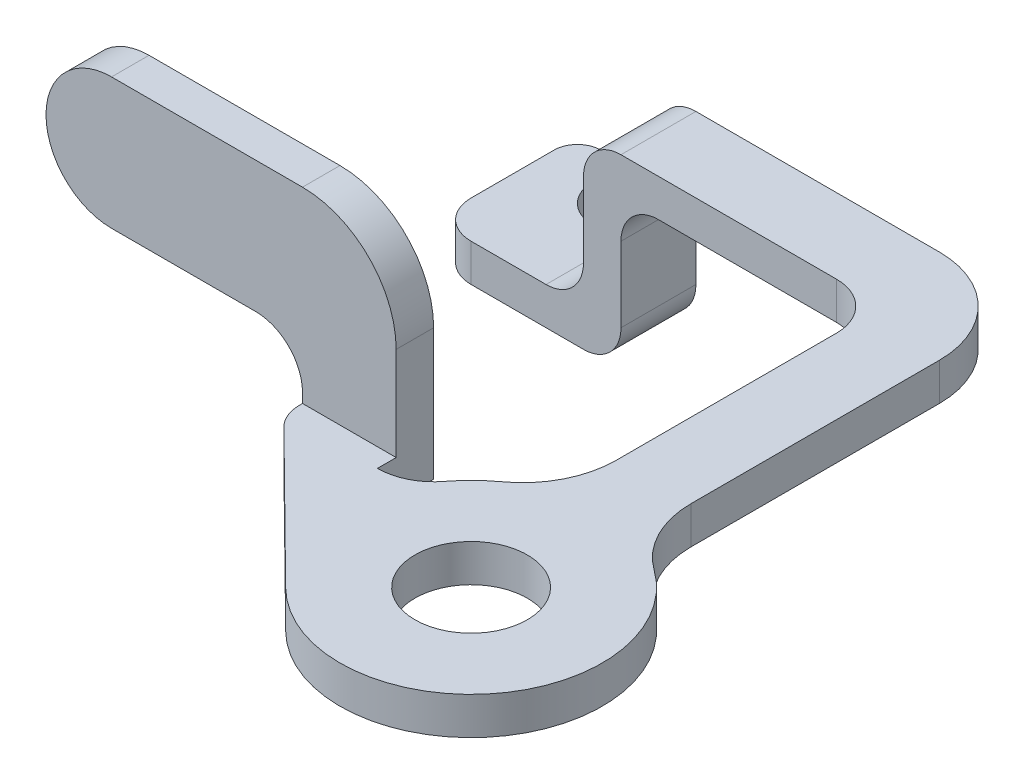
from build123d import *

# Parameters (mm, degrees)
CROQUIS1_R              = 3
SALIENTE_EXTRUIR1_DEPTH = 2
SALIENTE_EXTRUIR2_DEPTH = 2
REDONDEO1_R             = 5
REDONDEO2_R             = 2.5
REDONDEO3_R             = 5
REDONDEO4_R             = 5
REDONDEO5_R             = 2
REDONDEO6_R             = 5
REDONDEO7_R             = 2.5
SALIENTE_EXTRUIR3_DEPTH = 4
REDONDEO8_R             = 2
REDONDEO9_R             = 2
SALIENTE_EXTRUIR4_DEPTH = 2
REDONDEO10_R            = 2
CORTAR_EXTRUIR1_DEPTH   = 2


with BuildPart() as part:
    # Croquis1 → Saliente-Extruir1 (new body)
    with BuildSketch(Plane(origin=(0, 0, 0), x_dir=(1, 0, 0), z_dir=(0, 1, 0))):
        with BuildLine():
            Line((2, 16.626040067), (2, 6.708203932))
            ThreePointArc((2, 6.708203932), (6.023877075, -3.56551609), (-4.918618823, -4.980681567))
            Line((-4.918618823, -4.980681567), (-13, 3))
            Line((-13, 3), (-13, 4))
            Line((-13, 4), (-8, 4))
            Line((-8, 4), (-8, 3))
            ThreePointArc((-8, 3), (-6.658359214, 3.316718427), (-5.6, 4.2))
            ThreePointArc((-5.6, 4.2), (-4.001596149, 5.743450902), (-2, 6.708203932))
            Line((-2, 6.708203932), (-2, 24))
            Line((-2, 24), (-16, 24))
            Line((-16, 24), (-16, 28))
            Line((-16, 28), (2, 28))
            Line((2, 28), (2, 16.626040067))
        make_face()
        Circle(CROQUIS1_R, mode=Mode.SUBTRACT)
    extrude(amount=SALIENTE_EXTRUIR1_DEPTH)

    # Croquis2 → Saliente-Extruir2 (add)
    with BuildSketch(Plane(origin=(0, 0, -4), x_dir=(-1, 0, 0), z_dir=(0, 0, -1))):
        with BuildLine():
            Line((8, 2), (8, 12))
            Line((8, 12), (23.192528099, 12))
            ThreePointArc((23.192528099, 12), (26.692528099, 8.5), (23.192528099, 5))
            Line((23.192528099, 5), (13, 5))
            Line((13, 5), (13, 2))
            Line((13, 2), (13, 0))
            Line((13, 0), (8, 0))
            Line((8, 0), (8, 2))
        make_face()
    extrude(amount=SALIENTE_EXTRUIR2_DEPTH)

    # Redondeo1
    redondeo1_edges = [part.edges().sort_by_distance(p)[0] for p in [
        (-8, 12, -5),
    ]]
    fillet(redondeo1_edges, radius=REDONDEO1_R)

    # Redondeo2
    redondeo2_edges = [part.edges().sort_by_distance(p)[0] for p in [
        (-13, 5, -5),
    ]]
    fillet(redondeo2_edges, radius=REDONDEO2_R)

    # Redondeo3
    redondeo3_edges = [part.edges().sort_by_distance(p)[0] for p in [
        (2, 1, -6.708203932),
    ]]
    fillet(redondeo3_edges, radius=REDONDEO3_R)

    # Redondeo4
    redondeo4_edges = [part.edges().sort_by_distance(p)[0] for p in [
        (-2, 1, -6.708203932),
    ]]
    fillet(redondeo4_edges, radius=REDONDEO4_R)

    # Redondeo5
    redondeo5_edges = [part.edges().sort_by_distance(p)[0] for p in [
        (-13, 1, -3),
    ]]
    fillet(redondeo5_edges, radius=REDONDEO5_R)

    # Redondeo6
    redondeo6_edges = [part.edges().sort_by_distance(p)[0] for p in [
        (2, 1, -28),
    ]]
    fillet(redondeo6_edges, radius=REDONDEO6_R)

    # Redondeo7
    redondeo7_edges = [part.edges().sort_by_distance(p)[0] for p in [
        (-2, 1, -24),
    ]]
    fillet(redondeo7_edges, radius=REDONDEO7_R)

    # Croquis3 → Saliente-Extruir3 (add)
    with BuildSketch(Plane(origin=(0, 0, -28), x_dir=(-1, 0, 0), z_dir=(0, 0, -1))):
        with BuildLine():
            Line((16, 2), (16, 0))
            Line((16, 0), (16, -6))
            ThreePointArc((16, -6), (16.585786438, -7.414213562), (18, -8))
            Line((18, -8), (26, -8))
            Line((26, -8), (26, -6))
            Line((26, -6), (18, -6))
            Line((18, -6), (18, 0))
            ThreePointArc((18, 0), (17.414213562, 1.414213562), (16, 2))
        make_face()
    extrude(amount=-SALIENTE_EXTRUIR3_DEPTH)

    # Redondeo8
    redondeo8_edges = [part.edges().sort_by_distance(p)[0] for p in [
        (-18, -6, -26),
    ]]
    fillet(redondeo8_edges, radius=REDONDEO8_R)

    # Redondeo9
    redondeo9_edges = [part.edges().sort_by_distance(p)[0] for p in [
        (-16, 0, -26),
    ]]
    fillet(redondeo9_edges, radius=REDONDEO9_R)

    # Croquis4 → Saliente-Extruir4 (add)
    with BuildSketch(Plane(origin=(0, -6, 0), x_dir=(1, 0, 0), z_dir=(0, 1, 0))):
        with BuildLine():
            Line((-23.5, 28), (-23.5, 30.5))
            ThreePointArc((-23.5, 30.5), (-24.75, 31.677994798), (-26, 30.5))
            Line((-26, 30.5), (-26, 28))
            Line((-26, 28), (-23.5, 28))
        make_face()
    extrude(amount=-SALIENTE_EXTRUIR4_DEPTH)

    # Redondeo10
    redondeo10_edges = [part.edges().sort_by_distance(p)[0] for p in [
        (-23.5, -7, -28),
    ]]
    fillet(redondeo10_edges, radius=REDONDEO10_R)

    # Croquis5 → Cortar-Extruir1 (cut)
    with BuildSketch(Plane(origin=(0, -6, 0), x_dir=(1, 0, 0), z_dir=(0, 1, 0))):
        with BuildLine():
            Line((-26, 24), (-26, 26))
            ThreePointArc((-26, 26), (-25.414213562, 24.585786438), (-24, 24))
            Line((-24, 24), (-26, 24))
        make_face()
    extrude(amount=-CORTAR_EXTRUIR1_DEPTH, mode=Mode.SUBTRACT)


solid = part.part
